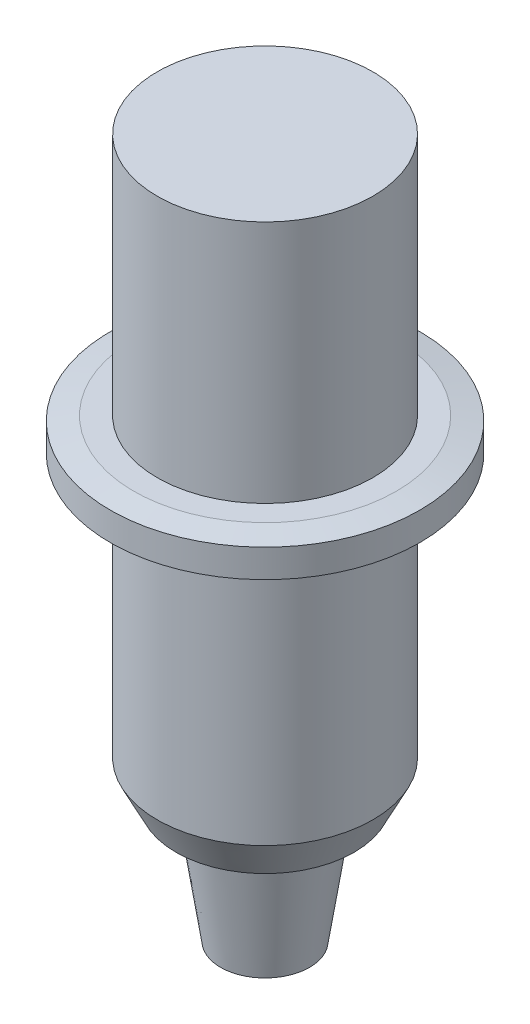
from build123d import *


with BuildPart() as part:
    # Sketch1 → 5.63 mm bottom to pen tip (revolve)
    with BuildSketch(Plane.XY):
        Polygon((0, 0), (2.375, 0), (3.2, 5.5), (3.2, 6.5), (4.75, 6.5), (5.75, 8.5), (5.75, 22.3), (7, 22.3), (8.25, 22.55), (8.25, 24.05), (7, 24.3), (5.75, 24.3), (5.75, 37.3), (0, 37.3), align=None)
    revolve(axis=Axis((0, -143.950460456, 0), (0, 1, 0)))


solid = part.part
